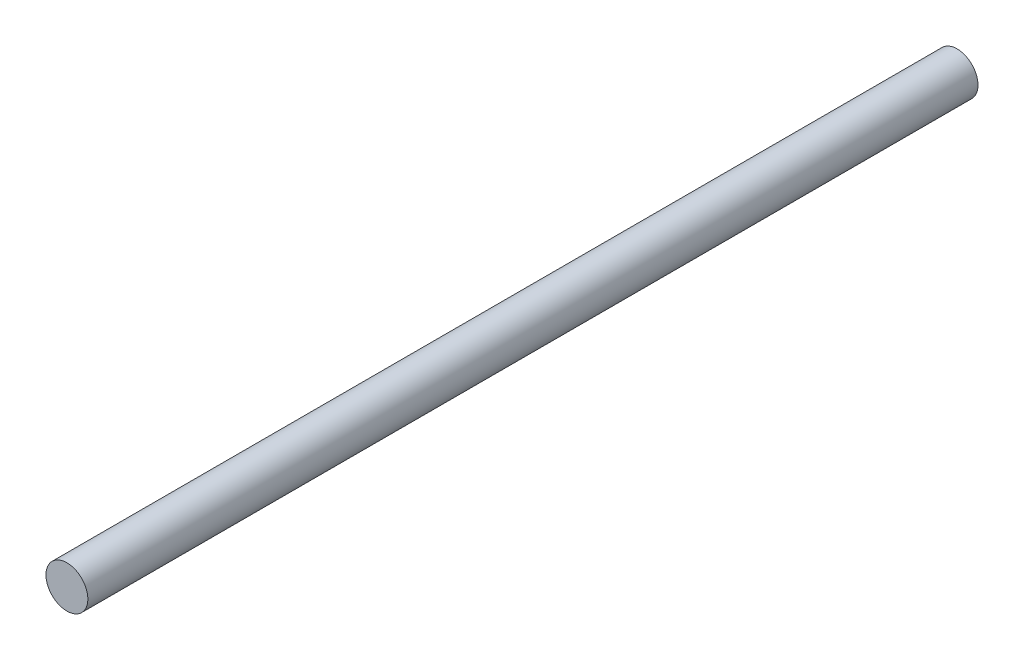
from build123d import *

# Parameters (mm, degrees)
SKETCH1_R  = 2
MAIN_DEPTH = 85


with BuildPart() as part:
    # Sketch1 → Main (new body)
    with BuildSketch(Plane.XY):
        Circle(SKETCH1_R)
    extrude(amount=MAIN_DEPTH)


solid = part.part
